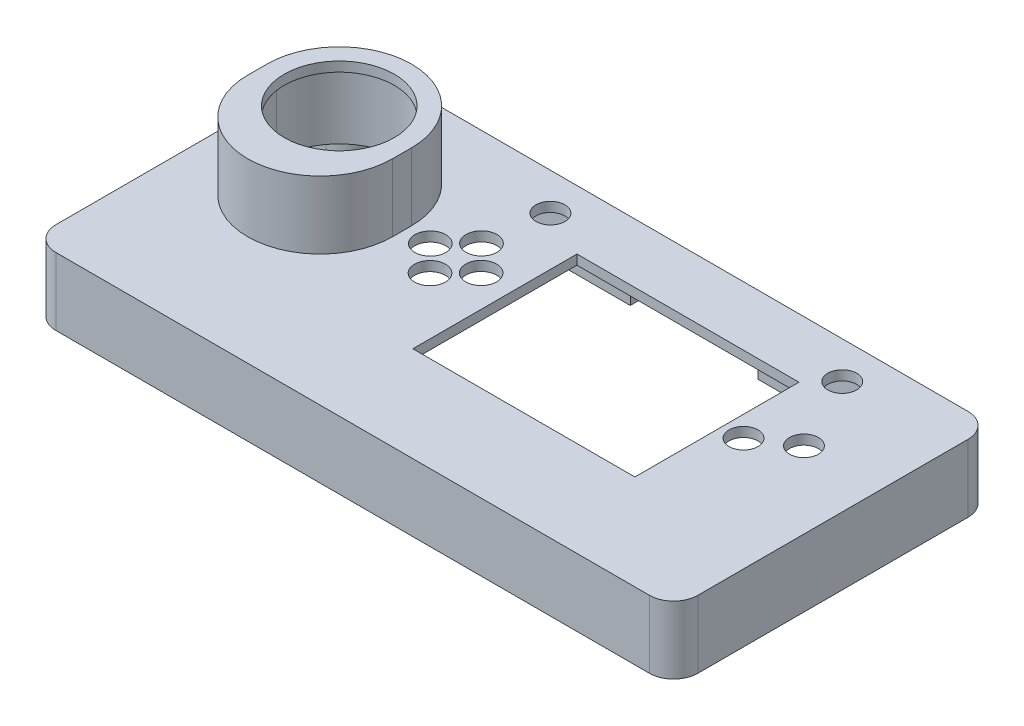
from build123d import *

# Parameters (mm, degrees)
SKETCH_1_R          = 3.2
SKETCH_1_R_2        = 3
SKETCH_1_W          = 46
SKETCH_1_H          = 34
EXTRUDE_1_DEPTH     = 13
SKETCH_2_R          = 11.4
EXTRUDE_2_DEPTH     = 14
SKETCH_3_R          = 1.25
CUT_EXTRUDE_1_DEPTH = 11
CUT_EXTRUDE_2_DEPTH = 14
SKETCH_5_R          = 4
EXTRUDE_3_DEPTH     = 2
SKETCH_6_R          = 1.5
EXTRUDE_4_DEPTH     = 5
EXTRUDE_5_DEPTH     = 1
SKETCH_9_W          = 26.5
SKETCH_9_H          = 7.251384336
CUT_EXTRUDE_4_DEPTH = 10


with BuildPart() as part:
    # 스케치1 → 보스-돌출1 (new body)
    with BuildSketch(Plane(origin=(0, 0, 0), x_dir=(1, 0, 0), z_dir=(0, 1, 0))):
        with BuildLine():
            Line((-61.498388188, 66.010476517), (61.501611812, 65.989522963))
            ThreePointArc((61.501611812, 65.989522963), (65.036624731, 64.524771992), (66.500805906, 60.989523028))
            Line((66.500805906, 60.989523028), (66.500805906, 4.989523158))
            ThreePointArc((66.500805906, 4.989523158), (65.03605487, 1.453704333), (61.5, -0.010476777))
            Line((61.5, -0.010476777), (-61.5, 0.010476777))
            ThreePointArc((-61.5, 0.010476777), (-65.035012919, 1.475227749), (-66.499194094, 5.010476712))
            Line((-66.499194094, 5.010476712), (-66.499194094, 61.010476582))
            ThreePointArc((-66.499194094, 61.010476582), (-65.034443058, 64.546295408), (-61.498388188, 66.010476517))
        make_face()
        with Locations((-19.054194094, 45.730282553)):
            Circle(SKETCH_1_R, mode=Mode.SUBTRACT)
        with Locations((-24.324694094, 40.396282553)):
            Circle(SKETCH_1_R, mode=Mode.SUBTRACT)
        with Locations((-13.783694094, 40.396282553)):
            Circle(SKETCH_1_R, mode=Mode.SUBTRACT)
        with Locations((-19.054194094, 35.062282553)):
            Circle(SKETCH_1_R, mode=Mode.SUBTRACT)
        with Locations((-17.339694094, 58.303282553)):
            Circle(SKETCH_1_R_2, mode=Mode.SUBTRACT)
        with Locations((43.112305906, 58.303282553)):
            Circle(SKETCH_1_R_2, mode=Mode.SUBTRACT)
        with Locations((50.675805906, 42.811282553)):
            Circle(SKETCH_1_R_2, mode=Mode.SUBTRACT)
        with Locations((43.048805906, 37.919782553)):
            Circle(SKETCH_1_R_2, mode=Mode.SUBTRACT)
        with Locations((15.743805906, 36.713282553)):
            Rectangle(SKETCH_1_W, SKETCH_1_H, mode=Mode.SUBTRACT)
    extrude(amount=EXTRUDE_1_DEPTH)

    # 스케치2 → 보스-돌출2 (add)
    with BuildSketch(Plane(origin=(0, 13, 0), x_dir=(1, 0, 0), z_dir=(0, 1, 0))):
        with BuildLine():
            ThreePointArc((-59.454194094, 37.696962121), (-55.060795812, 27.090360404), (-44.454194094, 22.696962121))
            ThreePointArc((-44.454194094, 22.696962121), (-33.847592376, 27.090360404), (-29.454194094, 37.696962121))
            Line((-29.454194094, 37.696962121), (-29.454194094, 41.666282553))
            ThreePointArc((-29.454194094, 41.666282553), (-44.454194094, 56.666282553), (-59.454194094, 41.666282553))
            Line((-59.454194094, 41.666282553), (-59.454194094, 37.696962121))
        make_face()
        with Locations((-44.454194094, 41.666282553)):
            Circle(SKETCH_2_R, mode=Mode.SUBTRACT)
    extrude(amount=EXTRUDE_2_DEPTH)

    # 스케치3 → 컷-돌출1 (cut)
    with BuildSketch(Plane.XZ):
        with Locations((-60.440145734, -59.928842317)):
            Circle(SKETCH_3_R)
        with Locations((-60.440145734, -6.092110978)):
            Circle(SKETCH_3_R)
        with Locations((60.442726529, -59.928842317)):
            Circle(SKETCH_3_R)
        with Locations((60.442726529, -6.092110978)):
            Circle(SKETCH_3_R)
        with BuildLine():
            Line((-56.500826452, -64.009622683), (56.500826452, -63.990377307))
            Line((56.500826452, -63.990377307), (56.500826452, -60.989502488))
            ThreePointArc((56.500826452, -60.989502488), (57.965286528, -57.453983111), (61.500805906, -55.989523034))
            Line((61.500805906, -55.989523034), (64.500805906, -55.989523034))
            Line((64.500805906, -55.989523034), (64.500805906, -9.989482066))
            Line((64.500805906, -9.989482066), (61.500805906, -9.989482066))
            ThreePointArc((61.500805906, -9.989482066), (57.965286528, -8.52502199), (56.500826452, -4.989502612))
            Line((56.500826452, -4.989502612), (56.500826452, -1.990377339))
            Line((56.500826452, -1.990377339), (-56.500826452, -2.009622715))
            Line((-56.500826452, -2.009622715), (-56.500826452, -4.989502612))
            ThreePointArc((-56.500826452, -4.989502612), (-57.965286528, -8.52502199), (-61.500805906, -9.989482066))
            Line((-61.500805906, -9.989482066), (-64.499194094, -9.989482066))
            Line((-64.499194094, -9.989482066), (-64.499194094, -55.989523034))
            Line((-64.499194094, -55.989523034), (-61.500805906, -55.989523034))
            ThreePointArc((-61.500805906, -55.989523034), (-57.965286528, -57.453983111), (-56.500826452, -60.989502488))
            Line((-56.500826452, -60.989502488), (-56.500826452, -64.009622683))
        make_face()
    extrude(amount=-CUT_EXTRUDE_1_DEPTH, mode=Mode.SUBTRACT)

    # 스케치4 → 컷-돌출2 (cut)
    with BuildSketch(Plane.XZ.offset(-11)):
        with BuildLine():
            Line((-31.454194094, -41.666282553), (-31.454194094, -37.696962121))
            ThreePointArc((-31.454194094, -37.696962121), (-35.261805939, -28.504573966), (-44.454194094, -24.696962121))
            ThreePointArc((-44.454194094, -24.696962121), (-53.646582249, -28.504573966), (-57.454194094, -37.696962121))
            Line((-57.454194094, -37.696962121), (-57.454194094, -41.666282553))
            ThreePointArc((-57.454194094, -41.666282553), (-44.454194094, -54.666282553), (-31.454194094, -41.666282553))
        make_face()
    extrude(amount=-CUT_EXTRUDE_2_DEPTH, mode=Mode.SUBTRACT)

    # 스케치5 → 보스-돌출3 (add)
    with BuildSketch(Plane.XZ.offset(-11)):
        with Locations((-26.039194094, -58.176282553)):
            Circle(SKETCH_5_R)
        with Locations((52.065805906, -58.176282553)):
            Circle(SKETCH_5_R)
        with Locations((-26.039194094, -11.821282553)):
            Circle(SKETCH_5_R)
        with Locations((52.065805906, -11.821282553)):
            Circle(SKETCH_5_R)
    extrude(amount=EXTRUDE_3_DEPTH)

    # 스케치6 → 보스-돌출4 (add)
    with BuildSketch(Plane.XZ.offset(-9)):
        with Locations((-26.039194094, -58.176282553)):
            Circle(SKETCH_6_R)
        with Locations((52.065805906, -58.176282553)):
            Circle(SKETCH_6_R)
        with Locations((52.065805906, -11.821282553)):
            Circle(SKETCH_6_R)
        with Locations((-26.039194094, -11.821282553)):
            Circle(SKETCH_6_R)
    extrude(amount=EXTRUDE_4_DEPTH)

    # 스케치8 → 보스-돌출5 (add)
    with BuildSketch(Plane.XZ):
        with BuildLine():
            Line((61.501611812, -65.989522963), (-61.498388188, -66.010476517))
            ThreePointArc((-61.498388188, -66.010476517), (-65.034443058, -64.546295408), (-66.499194094, -61.010476582))
            Line((-66.499194094, -61.010476582), (-66.499194094, -5.010476712))
            ThreePointArc((-66.499194094, -5.010476712), (-65.035012919, -1.475227749), (-61.5, -0.010476777))
            Line((-61.5, -0.010476777), (61.5, 0.010476777))
            ThreePointArc((61.5, 0.010476777), (65.03605487, -1.453704333), (66.500805906, -4.989523158))
            Line((66.500805906, -4.989523158), (66.500805906, -60.989523028))
            ThreePointArc((66.500805906, -60.989523028), (65.036624731, -64.524771992), (61.501611812, -65.989522963))
        make_face()
        with BuildLine():
            Line((-64.499194094, -5.010474033), (-64.499194094, -61.010473914))
            ThreePointArc((-64.499194094, -61.010473914), (-63.620333788, -63.131974892), (-61.498683162, -64.010473871))
            Line((-61.498683162, -64.010473871), (61.501316838, -63.989525671))
            ThreePointArc((61.501316838, -63.989525671), (63.622306883, -63.110665409), (64.500805906, -60.989525714))
            Line((64.500805906, -60.989525714), (64.500805906, -4.989525834))
            ThreePointArc((64.500805906, -4.989525834), (63.6219456, -2.868024856), (61.500294974, -1.989525877))
            Line((61.500294974, -1.989525877), (-61.499705026, -2.010474077))
            ThreePointArc((-61.499705026, -2.010474077), (-63.620695072, -2.889334339), (-64.499194094, -5.010474033))
        make_face(mode=Mode.SUBTRACT)
    extrude(amount=EXTRUDE_5_DEPTH)

    # 스케치9 → 컷-돌출4 (cut)
    with BuildSketch(Plane.XZ.offset(1)):
        with Locations((6.750805906, -65.426001526)):
            Rectangle(SKETCH_9_W, SKETCH_9_H)
    extrude(amount=-CUT_EXTRUDE_4_DEPTH, mode=Mode.SUBTRACT)


solid = part.part
